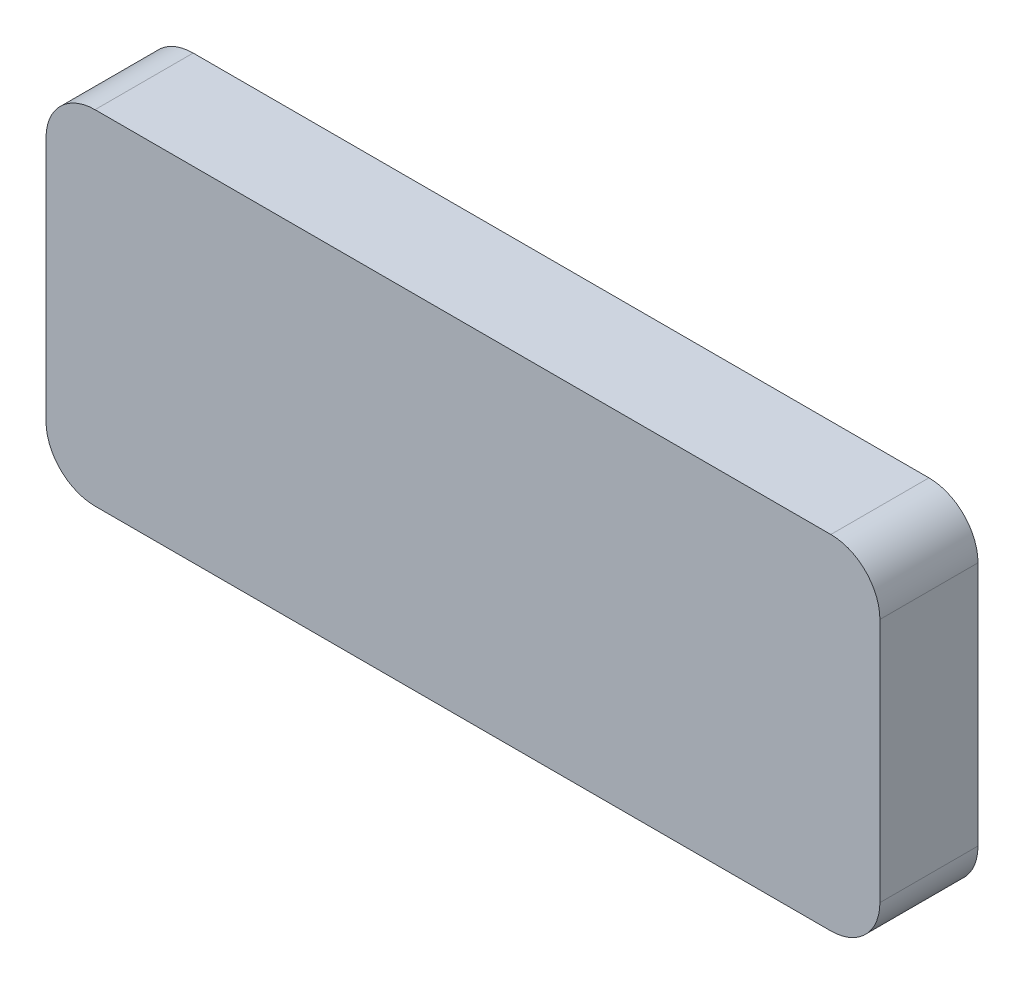
from build123d import *

# Parameters (mm, degrees)
SKETCH1_W      = 17
SKETCH1_H      = 7
EXTRUDE1_DEPTH = 2
FILLET1_R      = 1


with BuildPart() as part:
    # Sketch1 → Extrude1 (new body)
    with BuildSketch(Plane.XY):
        Rectangle(SKETCH1_W, SKETCH1_H)
    extrude(amount=EXTRUDE1_DEPTH)

    # Fillet1
    fillet1_edges = [part.edges().sort_by_distance(p)[0] for p in [
        (-8.5, 3.5, 1),
        (8.5, 3.5, 1),
        (8.5, -3.5, 1),
        (-8.5, -3.5, 1),
    ]]
    fillet(fillet1_edges, radius=FILLET1_R)


solid = part.part
